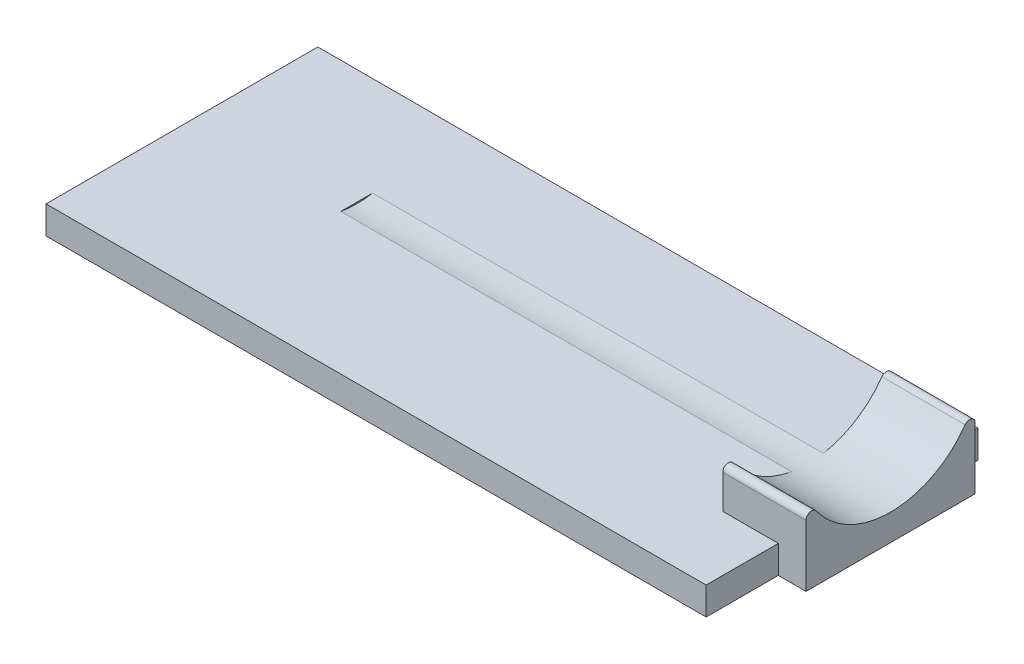
from build123d import *

# Parameters (mm, degrees)
SKETCH1_W           = 23.8
SKETCH1_H           = 9.8
BOSS_EXTRUDE1_DEPTH = 1
SKETCH2_W           = 3
SKETCH2_H           = 6.1
BOSS_EXTRUDE2_DEPTH = 3.25
SKETCH4_W           = 1
SKETCH4_H           = 6.1
BOSS_EXTRUDE3_DEPTH = 1
SKETCH3_R           = 3.3
CUT_EXTRUDE1_DEPTH  = 19.25
FILLET1_R           = 0.2


with BuildPart() as part:
    # Sketch1 → Boss-Extrude1 (new body)
    with BuildSketch(Plane(origin=(0, 0, 0), x_dir=(1, 0, 0), z_dir=(0, 1, 0))):
        with Locations((-11.9, 4.9)):
            Rectangle(SKETCH1_W, SKETCH1_H)
    extrude(amount=BOSS_EXTRUDE1_DEPTH)

    # Sketch2 → Boss-Extrude2 (add)
    with BuildSketch(Plane(origin=(0, 1, 0), x_dir=(1, 0, 0), z_dir=(0, 1, 0))):
        with Locations((-0.5, 5.65)):
            Rectangle(SKETCH2_W, SKETCH2_H)
    extrude(amount=BOSS_EXTRUDE2_DEPTH)

    # Sketch4 → Boss-Extrude3 (add)
    with BuildSketch(Plane.XZ.offset(-1)):
        with Locations((0.5, -5.65)):
            Rectangle(SKETCH4_W, SKETCH4_H)
    extrude(amount=BOSS_EXTRUDE3_DEPTH)

    # Sketch3 → Cut-Extrude1 (cut)
    with BuildSketch(Plane(origin=(1, 0, 0), x_dir=(0, 0, -1), z_dir=(1, 0, 0))):
        with Locations((5.65, 4.25)):
            Circle(SKETCH3_R)
    extrude(amount=-CUT_EXTRUDE1_DEPTH, mode=Mode.SUBTRACT)

    # Fillet1
    fillet1_edges = [part.edges().sort_by_distance(p)[0] for p in [
        (-0.5, 2.990039683, -2.6),
        (-0.5, 2.990039683, -8.7),
    ]]
    fillet(fillet1_edges, radius=FILLET1_R)


solid = part.part
